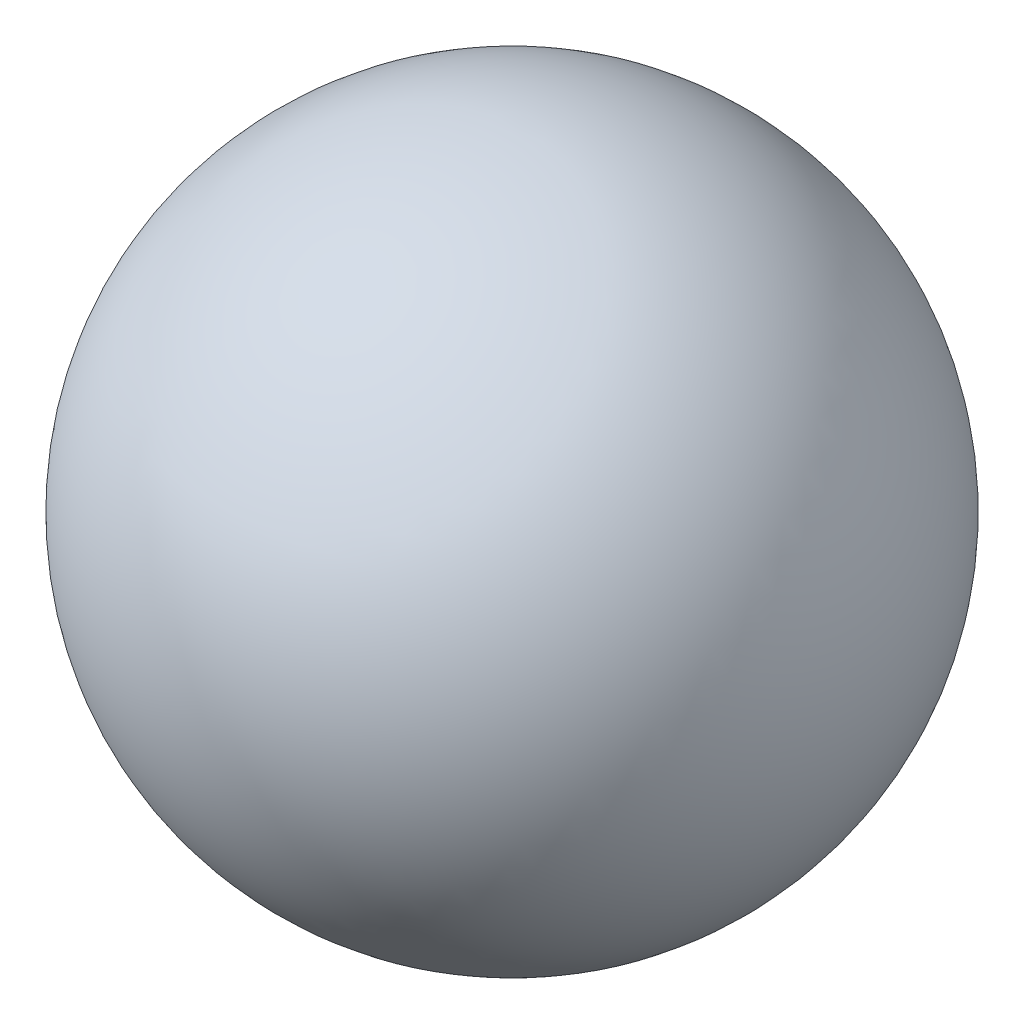
from build123d import *


with BuildPart() as part:
    # Sketch1 → Revolve1 (revolve)
    with BuildSketch(Plane.XY):
        with BuildLine():
            Line((0, 7.5), (0, -7.5))
            ThreePointArc((0, -7.5), (7.5, 0), (0, 7.5))
        make_face()
    revolve(axis=Axis((0, 10.830333015, 0), (0, -1, 0)))


solid = part.part
